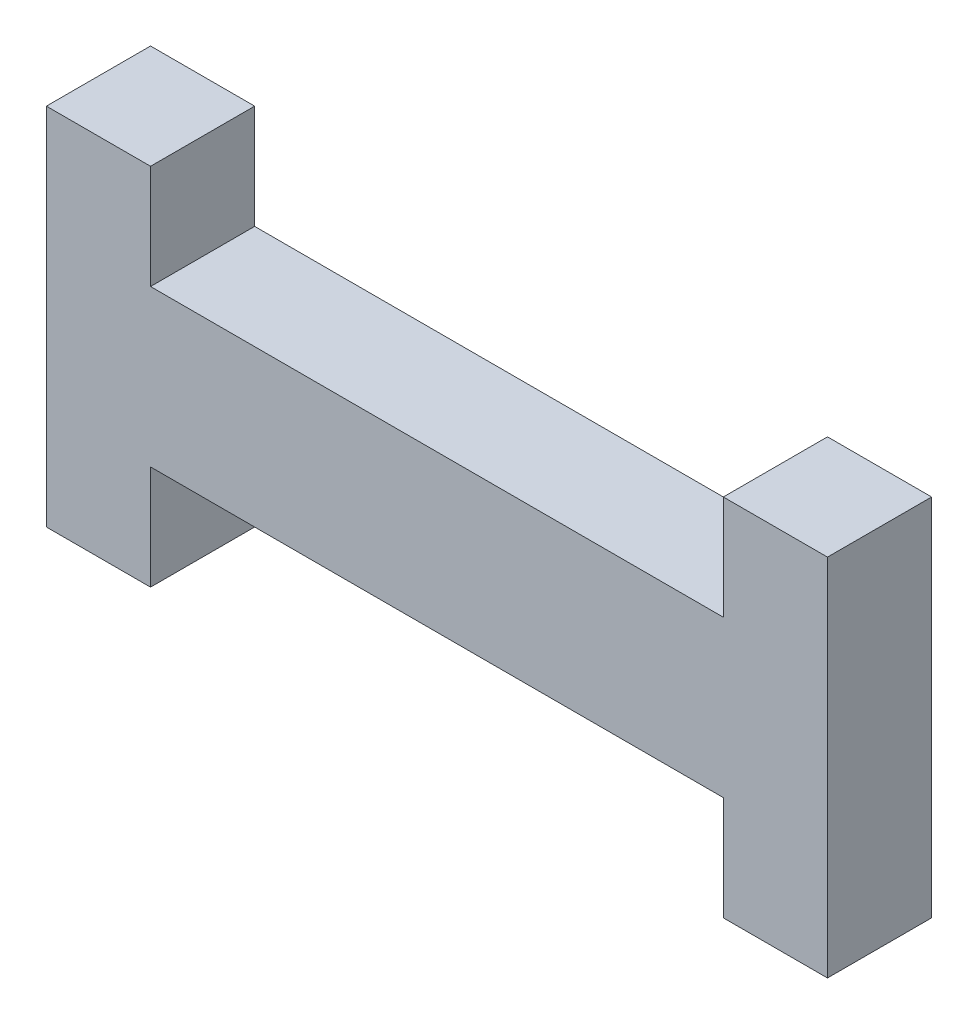
from build123d import *

# Parameters (mm, degrees)
BOSS_EXTRU_1_DEPTH = 2


with BuildPart() as part:
    # Esquisse1 → Boss.-Extru.1 (new body)
    with BuildSketch(Plane.XY):
        Polygon((0, 0), (11, 0), (11, 2), (13, 2), (13, -5), (11, -5), (11, -3), (0, -3), (0, -5), (-2, -5), (-2, 2), (0, 2), align=None)
    extrude(amount=BOSS_EXTRU_1_DEPTH)


solid = part.part
